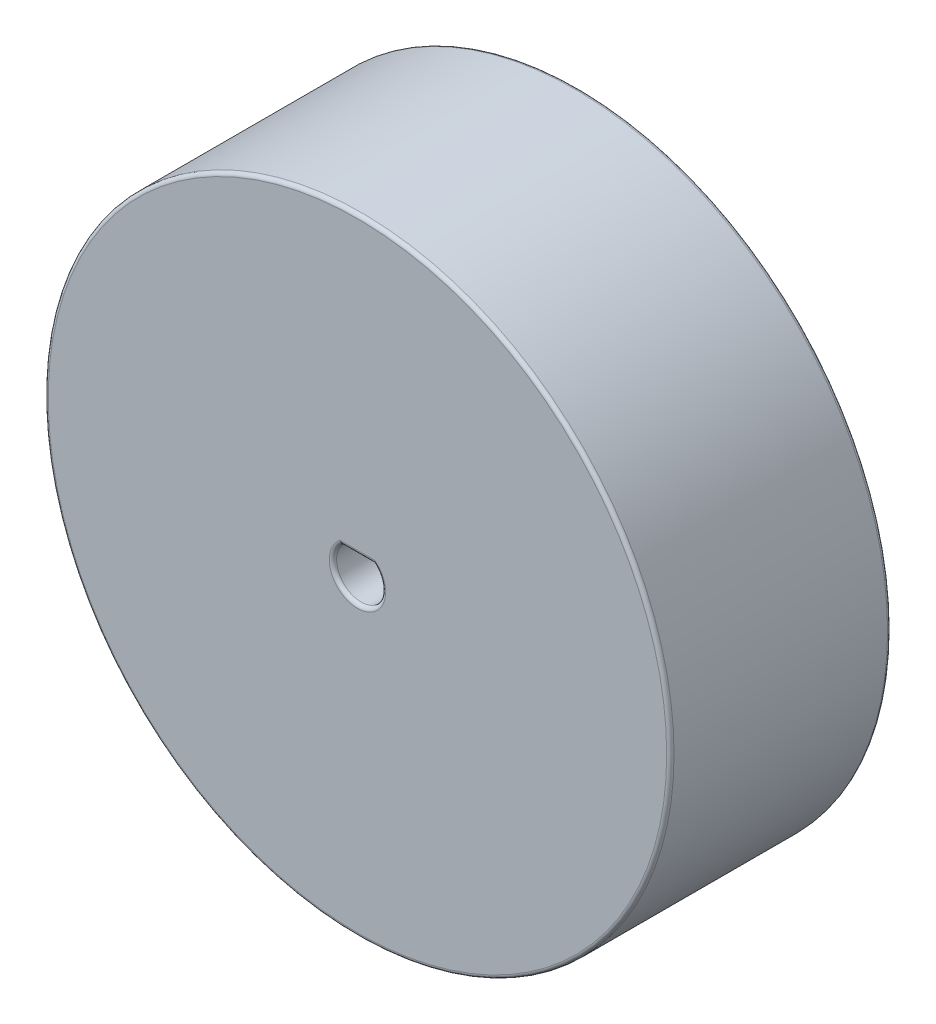
from build123d import *

# Parameters (mm, degrees)
ESQUISSE1_R             = 25.5
BOSS_EXTRU_1_DEPTH      = 18
ENL_V_MAT_EXTRU_2_DEPTH = 10
ENL_V_MAT_EXTRU_4_DEPTH = 5
CONG_1_R                = 0.3


with BuildPart() as part:
    # Esquisse1 → Boss.-Extru.1 (new body)
    with BuildSketch(Plane.XY):
        Circle(ESQUISSE1_R)
    extrude(amount=BOSS_EXTRU_1_DEPTH)

    # Esquisse2 → Enlèv. mat.-Extru.2 (cut)
    with BuildSketch(Plane.XY.offset(18)):
        with BuildLine():
            Line((1.322875656, 1.5), (-1.322875656, 1.5))
            ThreePointArc((-1.322875656, 1.5), (0, -2), (1.322875656, 1.5))
        make_face()
    extrude(amount=-ENL_V_MAT_EXTRU_2_DEPTH, mode=Mode.SUBTRACT)

    # Esquisse3 → Enlèv. mat.-Extru.4 (cut)
    with BuildSketch(Plane(origin=(0, 0, 0), x_dir=(-1, 0, 0), z_dir=(0, 0, -1))):
        with BuildLine():
            ThreePointArc((1.5, 3.708324452), (2.828574751, 2.828574751), (3.708324452, 1.5))
            Line((3.708324452, 1.5), (23.953079134, 1.5))
            ThreePointArc((23.953079134, 1.5), (16.970562748, 16.970562748), (1.5, 23.953079134))
            Line((1.5, 23.953079134), (1.5, 3.708324452))
        make_face()
        with BuildLine():
            Line((-23.953079134, 1.5), (-3.708324452, 1.5))
            ThreePointArc((-3.708324452, 1.5), (-2.828574751, 2.828574751), (-1.5, 3.708324452))
            Line((-1.5, 3.708324452), (-1.5, 23.953079134))
            ThreePointArc((-1.5, 23.953079134), (-16.970562748, 16.970562748), (-23.953079134, 1.5))
        make_face()
        with BuildLine():
            Line((-1.5, -23.953079134), (-1.5, -3.708324452))
            ThreePointArc((-1.5, -3.708324452), (-2.828574751, -2.828574751), (-3.708324452, -1.5))
            Line((-3.708324452, -1.5), (-23.953079134, -1.5))
            ThreePointArc((-23.953079134, -1.5), (-16.970562748, -16.970562748), (-1.5, -23.953079134))
        make_face()
        with BuildLine():
            ThreePointArc((3.708324452, -1.5), (2.828574751, -2.828574751), (1.5, -3.708324452))
            Line((1.5, -3.708324452), (1.5, -23.953079134))
            ThreePointArc((1.5, -23.953079134), (16.970562748, -16.970562748), (23.953079134, -1.5))
            Line((23.953079134, -1.5), (3.708324452, -1.5))
        make_face()
    extrude(amount=-ENL_V_MAT_EXTRU_4_DEPTH, mode=Mode.SUBTRACT)

    # Congé1
    cong_1_edges = [part.edges().sort_by_distance(p)[0] for p in [
        (-25.5, 0, 0),
        (-25.5, 0, 18),
        (0, -2, 18),
        (0, 1.5, 18),
    ]]
    fillet(cong_1_edges, radius=CONG_1_R)


solid = part.part
